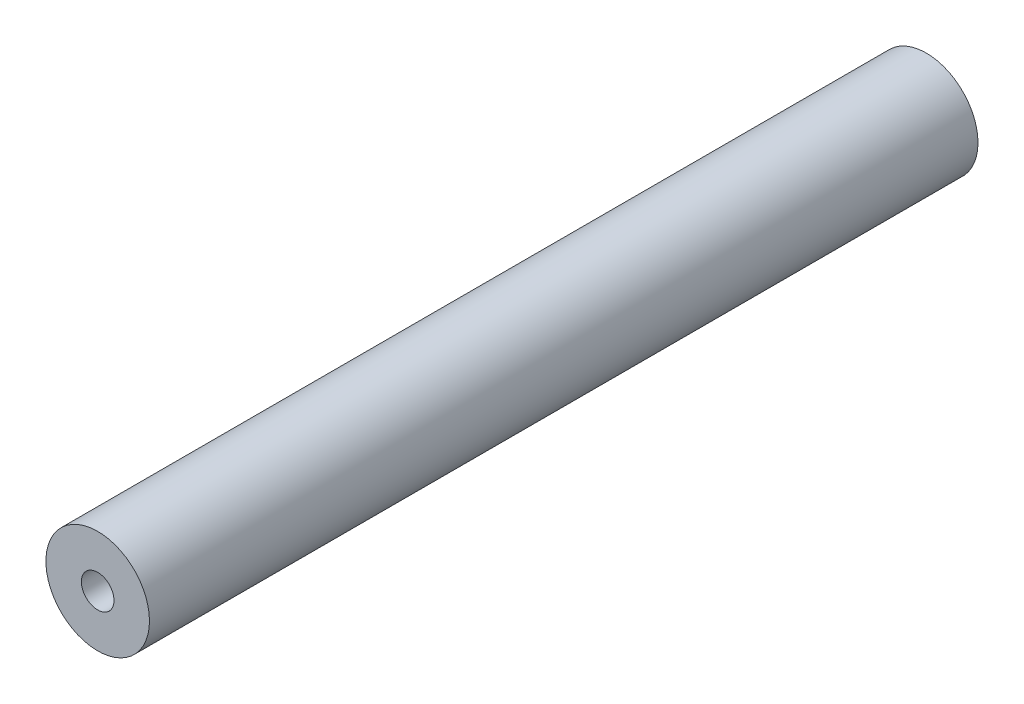
from build123d import *

# Parameters (mm, degrees)
SKETCH1_R           = 6.35
BOSS_EXTRUDE1_DEPTH = 101.6
SKETCH2_R           = 2
CUT_EXTRUDE1_DEPTH  = 102.6


with BuildPart() as part:
    # Sketch1 → Boss-Extrude1 (new body)
    with BuildSketch(Plane.XY):
        Circle(SKETCH1_R)
    extrude(amount=BOSS_EXTRUDE1_DEPTH)

    # Sketch2 → Cut-Extrude1 (cut, through all)
    with BuildSketch(Plane.XY.offset(101.6)):
        Circle(SKETCH2_R)
    extrude(amount=-CUT_EXTRUDE1_DEPTH, mode=Mode.SUBTRACT)


solid = part.part
